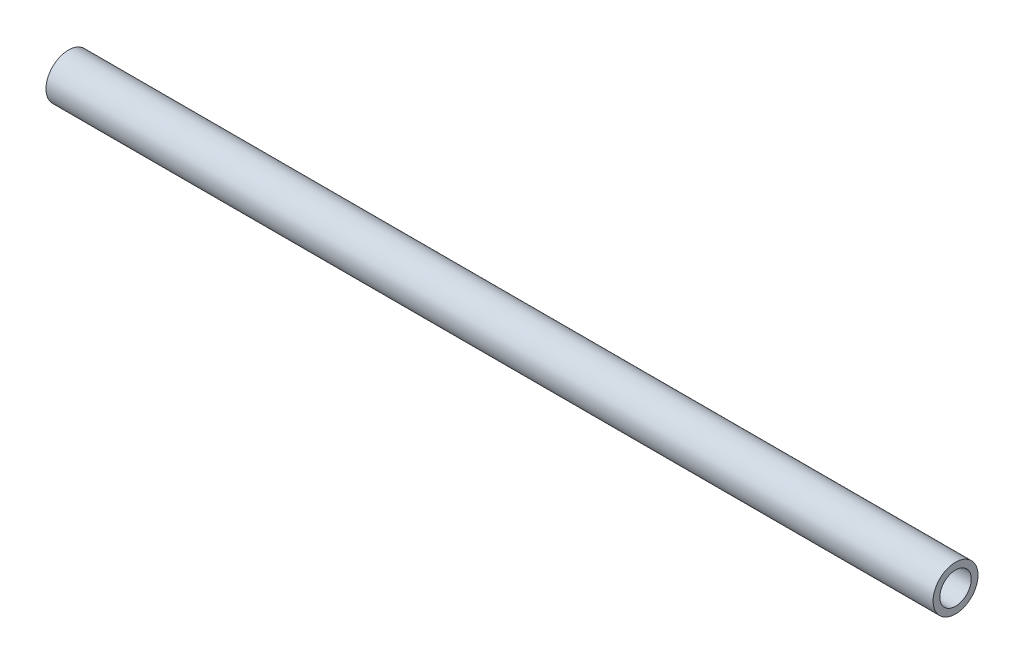
from build123d import *

# Parameters (mm, degrees)
SWEEP_THIN1_PROFILE_R   = 10
SWEEP_THIN1_PROFILE_R_2 = 7


with BuildPart() as part:
    # Sweep-Thin1: sweep along a path in Sketch1
    with BuildLine(Plane(origin=(0, 0, 0), x_dir=(1, 0, 0), z_dir=(0, 1, 0))) as sweep_thin1_path:
        Line((0, 0), (395, 0))
    # Sweep-Thin1 profile (on start of the path) → Sweep-Thin1 (sweep)
    with BuildSketch(Plane(origin=(0, 0, 0), x_dir=(0, 0, 1), z_dir=(1, 0, 0))):
        Circle(SWEEP_THIN1_PROFILE_R)
        Circle(SWEEP_THIN1_PROFILE_R_2, mode=Mode.SUBTRACT)
    sweep(path=sweep_thin1_path.line)


solid = part.part
